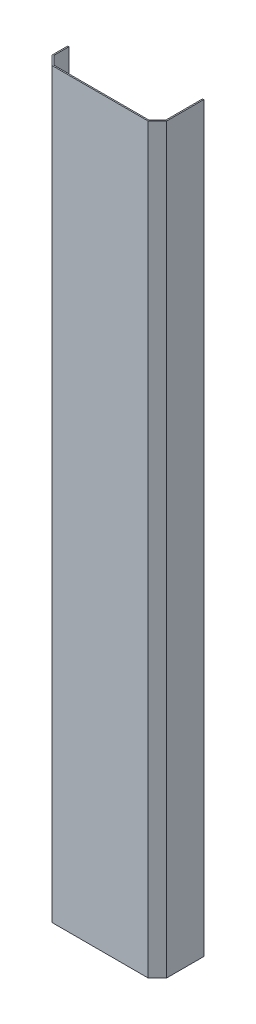
from build123d import *

# Parameters (mm, degrees)
BOSS_EXTRUDE1_DEPTH = 1200
CUT_EXTRUDE1_REACH  = 187
SKETCH2_W           = 20
SKETCH2_H           = 40


with BuildPart() as part:
    # Sketch1 → Boss-Extrude1 (new body)
    with BuildSketch(Plane(origin=(0, 0, 0), x_dir=(1, 0, 0), z_dir=(0, 1, 0))):
        Polygon((15.828427125, 2), (2, 15.828427125), (2, 40), (0, 40), (0, 15), (15, 0), (170, 0), (185, 15), (185, 75), (183, 75), (183, 15.828427125), (169.171572875, 2), align=None)
    extrude(amount=BOSS_EXTRUDE1_DEPTH)

    # Sketch2 → Cut-Extrude1 (cut, up to next)
    with BuildSketch(Plane.ZY, mode=Mode.PRIVATE) as cut_extrude1_sk1:
        with Locations((-30, 200)):
            Rectangle(SKETCH2_W, SKETCH2_H)
    cut_extrude1_tool1 = extrude(cut_extrude1_sk1.sketch, amount=-CUT_EXTRUDE1_REACH, mode=Mode.PRIVATE) & part.part
    add(cut_extrude1_tool1.solids().sort_by_distance((0, 200, -30))[0], mode=Mode.SUBTRACT)
    # Sketch2 → Cut-Extrude1 (cut, up to next)
    with BuildSketch(Plane.ZY, mode=Mode.PRIVATE) as cut_extrude1_sk2:
        with Locations((-30, 1135)):
            Rectangle(SKETCH2_W, SKETCH2_H)
    cut_extrude1_tool2 = extrude(cut_extrude1_sk2.sketch, amount=-CUT_EXTRUDE1_REACH, mode=Mode.PRIVATE) & part.part
    add(cut_extrude1_tool2.solids().sort_by_distance((0, 1135, -30))[0], mode=Mode.SUBTRACT)


solid = part.part
